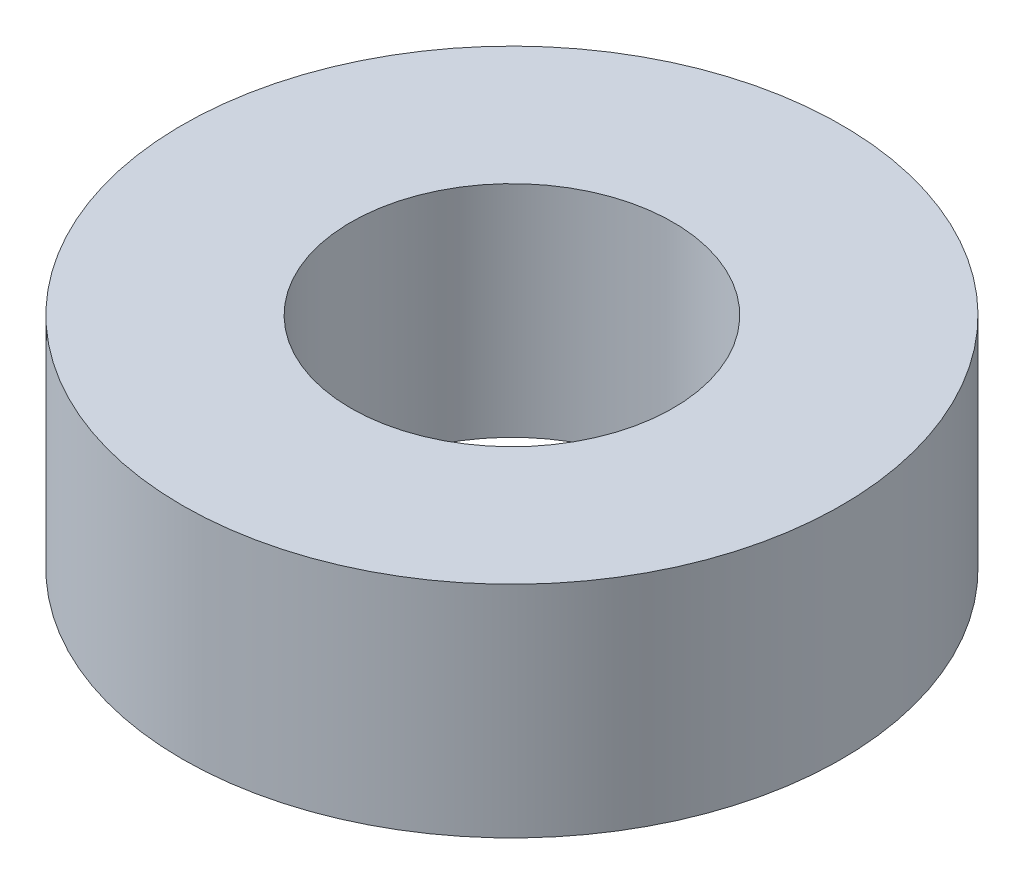
from build123d import *

# Parameters (mm, degrees)
SKETCH2_R           = 4.5
SKETCH2_R_2         = 2.2
BOSS_EXTRUDE1_DEPTH = 3


with BuildPart() as part:
    # Sketch2 → Boss-Extrude1 (new body)
    with BuildSketch(Plane(origin=(0, 0, 0), x_dir=(1, 0, 0), z_dir=(0, 1, 0))):
        Circle(SKETCH2_R)
        Circle(SKETCH2_R_2, mode=Mode.SUBTRACT)
    extrude(amount=BOSS_EXTRUDE1_DEPTH)


solid = part.part
